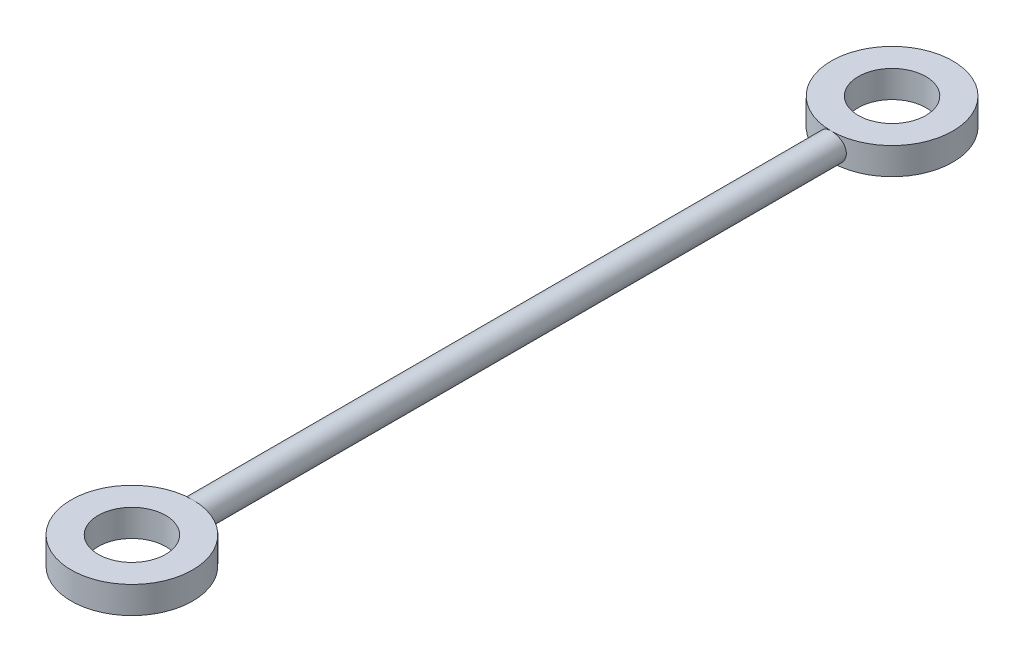
from build123d import *

# Parameters (mm, degrees)
SKETCH1_R           = 10
BOSS_EXTRUDE1_DEPTH = 493
SKETCH2_W           = 20
SKETCH2_H           = 20
SKETCH3_W           = 20
SKETCH3_H           = 20


with BuildPart() as part:
    # Sketch1 → Boss-Extrude1 (new body)
    with BuildSketch(Plane.XY):
        Circle(SKETCH1_R)
    extrude(amount=BOSS_EXTRUDE1_DEPTH)

    # Sketch2 → Revolve1 (revolve)
    with BuildSketch(Plane(origin=(0, 0, 0), x_dir=(0, 0, -1), z_dir=(1, 0, 0))):
        with Locations((-493, 0)):
            Rectangle(SKETCH2_W, SKETCH2_H)
    revolve(axis=Axis((0, 0, 528), (0, 1, 0)))

    # Sketch3 → Revolve2 (revolve)
    with BuildSketch(Plane(origin=(0, 0, 0), x_dir=(0, 0, -1), z_dir=(1, 0, 0))):
        Rectangle(SKETCH3_W, SKETCH3_H)
    revolve(axis=Axis((0, 0, -35), (0, 1, 0)))


solid = part.part
